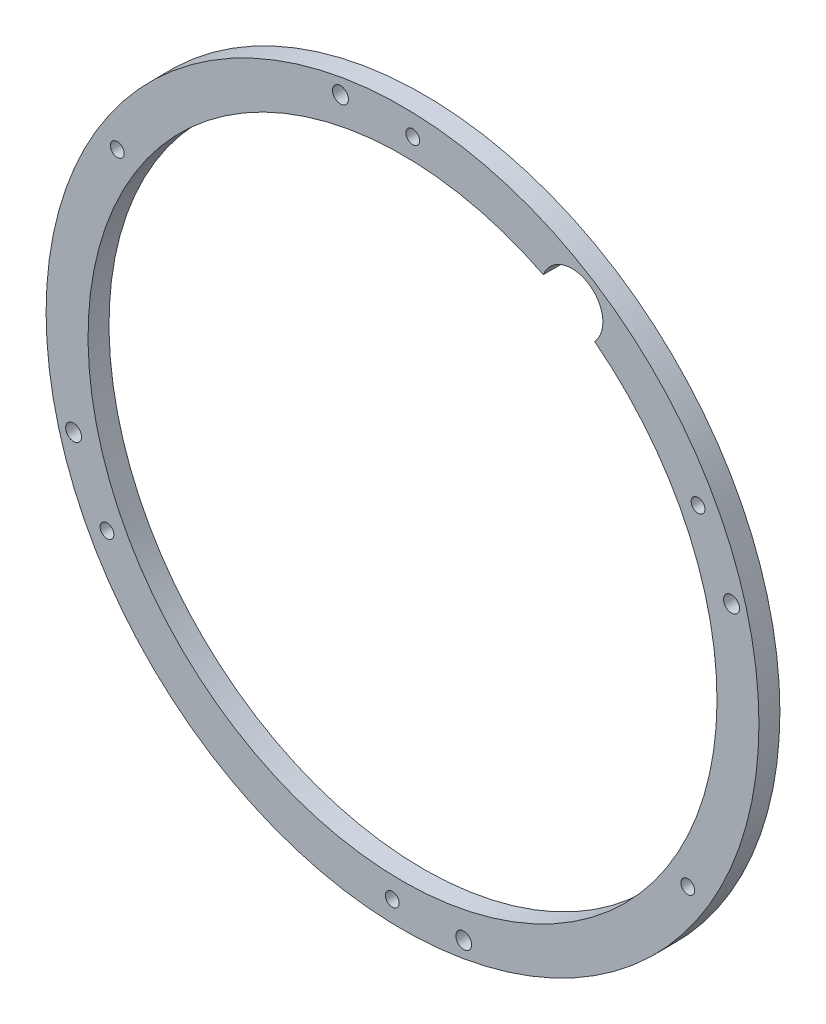
from build123d import *

# Parameters (mm, degrees)
SKETCH1_R           = 107.95
SKETCH1_R_2         = 95.25
BOSS_EXTRUDE1_DEPTH = 6.35
SKETCH2_R           = 2.085
SKETCH2_R_2         = 2.413
CUT_EXTRUDE1_DEPTH  = 21.336
SKETCH3_R           = 9.338597003
CUT_EXTRUDE2_DEPTH  = 7.35
SKETCH4_R           = 2.413
CUT_EXTRUDE3_DEPTH  = 6.35


with BuildPart() as part:
    # Sketch1 → Boss-Extrude1 (new body)
    with BuildSketch(Plane.XY):
        with Locations((14.57950887, 23.250008023)):
            Circle(SKETCH1_R)
        with Locations((14.57950887, 23.250008023)):
            Circle(SKETCH1_R_2, mode=Mode.SUBTRACT)
    extrude(amount=BOSS_EXTRUDE1_DEPTH)

    # Sketch2 → Cut-Extrude1 (cut)
    with BuildSketch(Plane(origin=(0, 0, 0), x_dir=(-1, 0, 0), z_dir=(0, 0, -1))):
        with Locations((-104.081912459, 71.332018712)):
            Circle(SKETCH2_R)
        with Locations((-17.690467943, 124.802368575)):
            Circle(SKETCH2_R)
        with Locations((71.811935646, 76.720357886)):
            Circle(SKETCH2_R)
        with Locations((74.922894719, -24.832002665)):
            Circle(SKETCH2_R)
        with Locations((-11.468549797, -78.302352529)):
            Circle(SKETCH2_R)
        with Locations((-100.970953386, -30.22034184)):
            Circle(SKETCH2_R)
        with Locations((4.215773698, 124.891191499)):
            Circle(SKETCH2_R_2)
        with Locations((-114.220260226, 50.557967298)):
            Circle(SKETCH2_R_2)
    extrude(amount=-CUT_EXTRUDE1_DEPTH, mode=Mode.SUBTRACT)

    # Sketch3 → Cut-Extrude2 (cut, through all)
    with BuildSketch(Plane(origin=(0, 0, 0), x_dir=(-1, 0, 0), z_dir=(0, 0, -1))):
        with Locations((-65.924155814, 105.010280384)):
            Circle(SKETCH3_R)
    extrude(amount=-CUT_EXTRUDE2_DEPTH, mode=Mode.SUBTRACT)

    # Sketch4 → Cut-Extrude3 (cut)
    with BuildSketch(Plane.XY.offset(6.35)):
        with Locations((33.116626404, -78.229145041)):
            Circle(SKETCH4_R)
        with Locations((-85.036904703, -4.073226214)):
            Circle(SKETCH4_R)
    extrude(amount=-CUT_EXTRUDE3_DEPTH, mode=Mode.SUBTRACT)


solid = part.part
